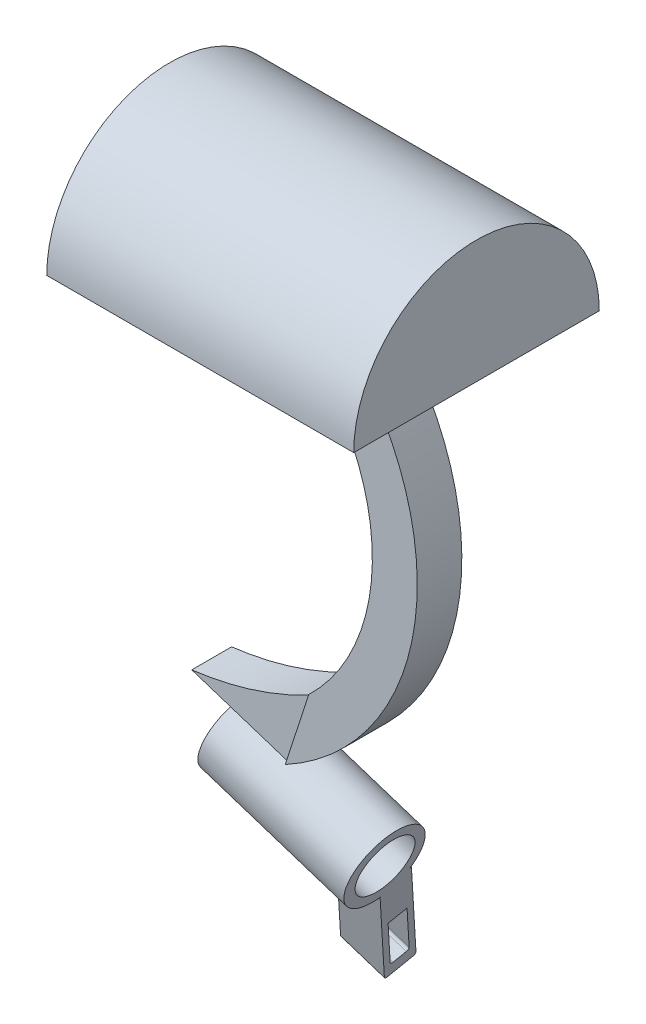
from build123d import *

# Parameters (mm, degrees)
SKETCH1_W               = 25.4
SKETCH1_H               = 10.16
REVOLVE1_ANGLE          = 180
SKETCH4_W               = 6.29000012
SKETCH4_H               = 3.69
SKETCH6_W               = 3.294985449
SKETCH6_H               = 5.974962046
BOSS_EXTRUDE1_DEPTH     = 5.08
SKETCH7_R               = 3.22
BOSS_EXTRUDE7_DEPTH     = 12.7
SKETCH9_W               = 3.294985449
SKETCH9_H               = 5.974962046
BOSS_EXTRUDE8_DEPTH     = 3.302
CUT_EXTRUDE1_DEPTH      = 3.302
CUT_EXTRUDE1_DEPTH_BACK = 3.302
SKETCH11_R              = 2.375
CUT_EXTRUDE2_DEPTH      = 2.54
CUT_EXTRUDE2_DEPTH_BACK = 12.446
BOSS_EXTRUDE14_DEPTH    = 3.81
SKETCH15_R              = 2.375
CUT_EXTRUDE3_DEPTH      = 22.352


with BuildPart() as part:
    # Sketch1 → Revolve1 (revolve)
    with BuildSketch(Plane(origin=(0, 0, 0), x_dir=(1, 0, 0), z_dir=(0, 1, 0))):
        with Locations((12.7, 5.451011236)):
            Rectangle(SKETCH1_W, SKETCH1_H)
    revolve(axis=Axis((0, 0, -0.371011236), (1, 0, 0)), revolution_arc=REVOLVE1_ANGLE)

    # Sweep1: sweep along a path in Sketch5
    with BuildLine(Plane.XY) as sweep1_path:
        ThreePointArc((12.7, 0), (20.315428689, -15.331843414), (12.392600359, -30.5071183))
    # Sketch4 → Sweep1 (sweep)
    with BuildSketch(Plane(origin=(0, 0, 0), x_dir=(1, 0, 0), z_dir=(0, 1, 0))):
        with Locations((12.7, 0.371011236)):
            Rectangle(SKETCH4_W, SKETCH4_H)
    sweep(path=sweep1_path.line)

    # Sketch6 → Boss-Extrude1 (add)
    with BuildSketch(Plane(origin=(20.164340987, -6.538110874, 0), x_dir=(0, 0, 1), z_dir=(-0.95124601, 0.308433183, 0))):
        with Locations((-0.361104817, -25.204906835)):
            Rectangle(SKETCH6_W, SKETCH6_H)
    extrude(amount=BOSS_EXTRUDE1_DEPTH)

    # Sketch7 → Boss-Extrude7 (add)
    with BuildSketch(Plane(origin=(15.332011256, -4.971270302, 0), x_dir=(0, 0, 1), z_dir=(-0.95124601, 0.308433183, 0))):
        with Locations((-0.361104816, -31.160979548)):
            Circle(SKETCH7_R)
    extrude(amount=-BOSS_EXTRUDE7_DEPTH)

    # Sketch9 → Boss-Extrude8 (add)
    with BuildSketch(Plane(origin=(15.332011256, -4.971270302, 0), x_dir=(0, 0, 1), z_dir=(-0.95124601, 0.308433183, 0))):
        with Locations((-0.361104817, -25.204906835)):
            Rectangle(SKETCH9_W, SKETCH9_H)
    extrude(amount=BOSS_EXTRUDE8_DEPTH)

    # Sketch10 → Cut-Extrude1 (cut, two sides)
    with BuildSketch(Plane.XY) as cut_extrude1_sk:
        with BuildLine():
            Line((3.495528998, -30.770720391), (5.338405562, -25.087061585))
            Line((5.338405562, -25.087061585), (13.311749617, -27.672348528))
            add(Edge.make_bspline(
                [(13.311749617, -27.672348528), (8.683653097, -30.129373505), (3.495528998, -30.770720391)],
                knots=[0, 0, 0, 1, 1, 1], degree=2))
        make_face()
    extrude(amount=CUT_EXTRUDE1_DEPTH, mode=Mode.SUBTRACT)
    extrude(cut_extrude1_sk.sketch, amount=-CUT_EXTRUDE1_DEPTH_BACK, mode=Mode.SUBTRACT)

    # Sketch11 → Cut-Extrude2 (cut, two sides)
    with BuildSketch(Plane(origin=(27.412835582, -8.888371731, 0), x_dir=(0, 0, -1), z_dir=(0.95124601, -0.308433183, 0))) as cut_extrude2_sk:
        with Locations((0.39169909, -31.12675273)):
            Circle(SKETCH11_R)
    extrude(amount=CUT_EXTRUDE2_DEPTH, mode=Mode.SUBTRACT)
    extrude(cut_extrude2_sk.sketch, amount=-CUT_EXTRUDE2_DEPTH_BACK, mode=Mode.SUBTRACT)

    # Sketch13 → Boss-Extrude14 (add)
    with BuildSketch(Plane(origin=(27.412835582, -8.888371731, 0), x_dir=(0, 0, -1), z_dir=(0.95124601, -0.308433183, 0))):
        with BuildLine():
            Line((6.519856112, -42.694953789), (3.125271975, -32.910924296))
            Line((3.125271975, -32.910924296), (0.972674671, -34.333593678))
            Line((0.972674671, -34.333593678), (4.157973921, -43.514412461))
            ThreePointArc((4.157973921, -43.514412461), (4.274214649, -43.645179802), (4.448875729, -43.655451668))
            Line((4.448875729, -43.655451668), (6.378816905, -42.985855597))
            ThreePointArc((6.378816905, -42.985855597), (6.509584246, -42.869614869), (6.519856112, -42.694953789))
        make_face()
        with BuildLine():
            Line((4.098849122, -37.242411221), (5.662835166, -41.750205096))
            ThreePointArc((5.662835166, -41.750205096), (5.6525633, -41.924866176), (5.521795959, -42.041106905))
            Line((5.521795959, -42.041106905), (4.53660766, -42.382919506))
            ThreePointArc((4.53660766, -42.382919506), (4.361946579, -42.37264764), (4.245705851, -42.241880299))
            Line((4.245705851, -42.241880299), (2.681719808, -37.734086425))
            Line((2.681719808, -37.734086425), (4.098849122, -37.242411221))
        make_face(mode=Mode.SUBTRACT)
    extrude(amount=-BOSS_EXTRUDE14_DEPTH)

    # Sketch15 → Cut-Extrude3 (cut)
    with BuildSketch(Plane(origin=(27.412835582, -8.888371731, 0), x_dir=(0, 0, -1), z_dir=(0.95124601, -0.308433183, 0))):
        with Locations((0.39169909, -31.12675273)):
            Circle(SKETCH15_R)
    extrude(amount=-CUT_EXTRUDE3_DEPTH, mode=Mode.SUBTRACT)


solid = part.part
